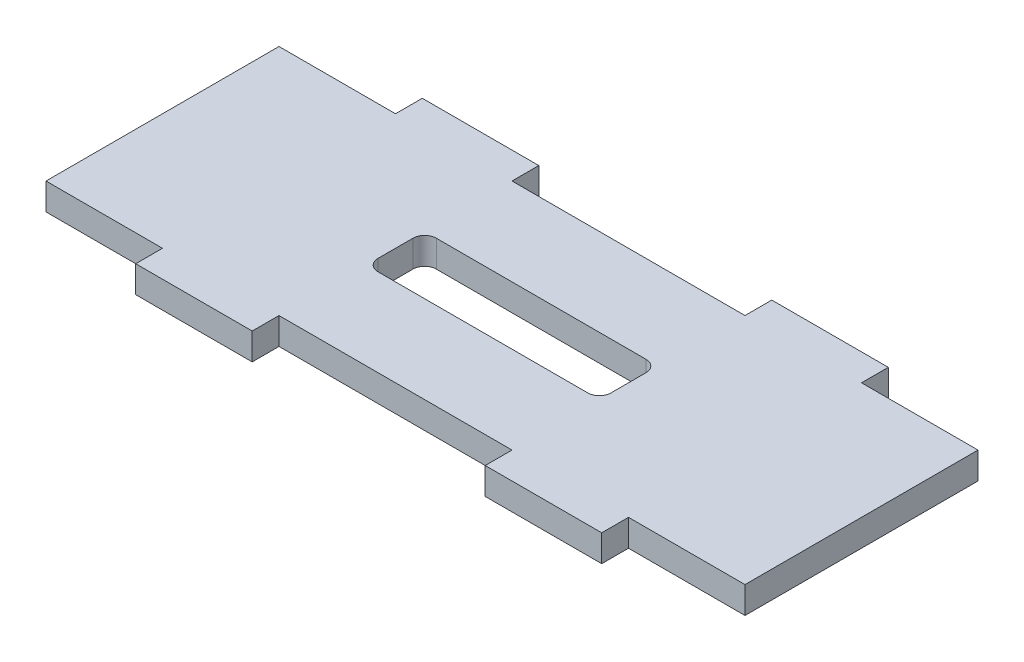
from build123d import *

# Parameters (mm, degrees)
BOSS_EXTRUDE1_DEPTH = 2.3
SKETCH2_W           = 20
SKETCH2_H           = 5
CUT_EXTRUDE1_DEPTH  = 10
FILLET1_R           = 1


with BuildPart() as part:
    # Sketch1 → Boss-Extrude1 (new body)
    with BuildSketch(Plane(origin=(0, 0, 0), x_dir=(1, 0, 0), z_dir=(0, 1, 0))):
        Polygon((0, 0), (0, 20), (10, 20), (10, 22.3), (20, 22.3), (20, 20), (40, 20), (40, 22.3), (50, 22.3), (50, 20), (60, 20), (60, 0), (50, 0), (50, -2.3), (40, -2.3), (40, 0), (20, 0), (20, -2.3), (10, -2.3), (10, 0), align=None)
    extrude(amount=BOSS_EXTRUDE1_DEPTH)

    # Sketch2 → Cut-Extrude1 (cut)
    with BuildSketch(Plane(origin=(0, 2.3, 0), x_dir=(1, 0, 0), z_dir=(0, 1, 0))):
        with Locations((30, 10)):
            Rectangle(SKETCH2_W, SKETCH2_H)
    extrude(amount=-CUT_EXTRUDE1_DEPTH, mode=Mode.SUBTRACT)

    # Fillet1
    fillet1_edges = [part.edges().sort_by_distance(p)[0] for p in [
        (20, 1.15, -12.5),
        (40, 1.15, -12.5),
        (40, 1.15, -7.5),
        (20, 1.15, -7.5),
    ]]
    fillet(fillet1_edges, radius=FILLET1_R)


solid = part.part
